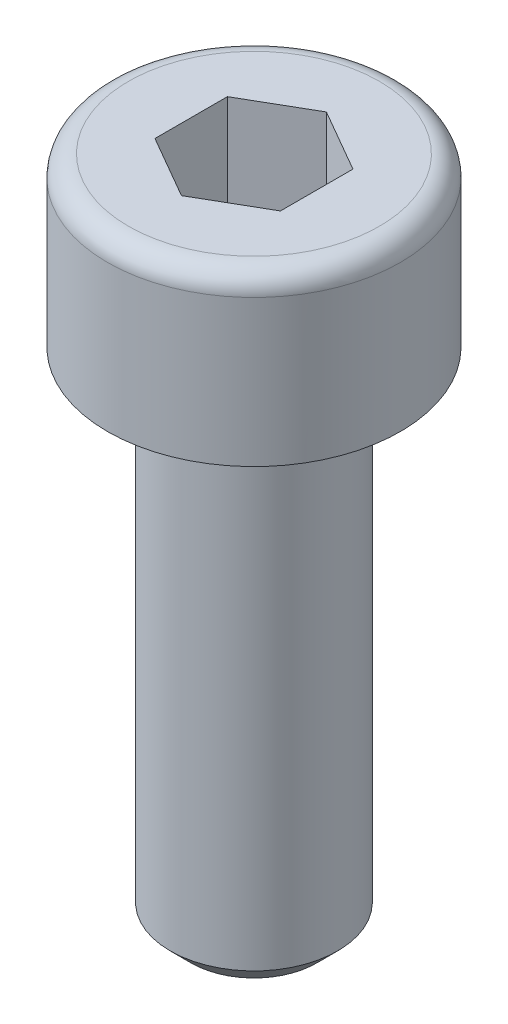
from build123d import *

# Parameters (mm, degrees)
CORTAR_EXTRUIR1_DEPTH = 3
CHAFL_N1_SIZE         = 0.5
REDONDEO1_R           = 0.5


with BuildPart() as part:
    # Croquis1 → Revolución1 (revolve)
    with BuildSketch(Plane.XY):
        Polygon((0, 0), (3.5, 0), (3.5, -4), (2, -4), (2, -16), (0, -16), align=None)
    revolve(axis=Axis((0, 0, 0), (0, -1, 0)))

    # Croquis2 → Cortar-Extruir1 (cut)
    with BuildSketch(Plane(origin=(0, 0, 0), x_dir=(1, 0, 0), z_dir=(0, 1, 0))):
        Polygon((1.5, 0.866025404), (0, 1.732050808), (-1.5, 0.866025404), (-1.5, -0.866025404), (0, -1.732050808), (1.5, -0.866025404), align=None)
    extrude(amount=-CORTAR_EXTRUIR1_DEPTH, mode=Mode.SUBTRACT)

    # Chaflán1
    chafl_n1_edges = [part.edges().sort_by_distance(p)[0] for p in [
        (-2, -16, 0),
    ]]
    chamfer(chafl_n1_edges, length=CHAFL_N1_SIZE)

    # Redondeo1
    redondeo1_edges = [part.edges().sort_by_distance(p)[0] for p in [
        (-3.5, 0, 0),
    ]]
    fillet(redondeo1_edges, radius=REDONDEO1_R)


solid = part.part
